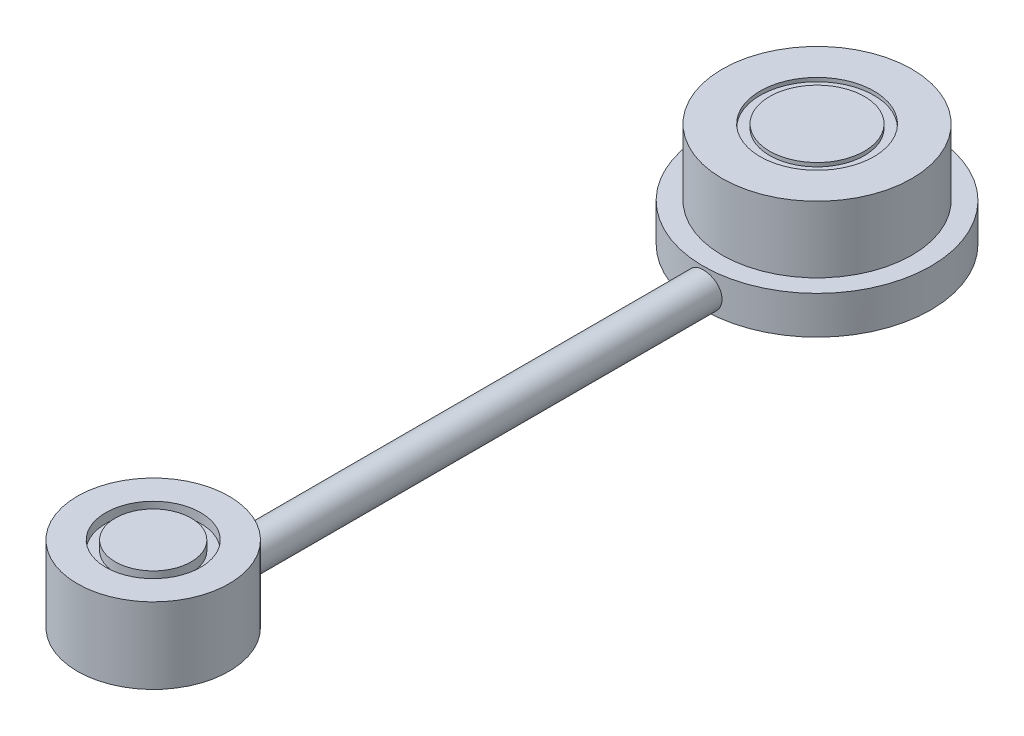
from build123d import *

# Parameters (mm, degrees)
SKETCH2_R            = 15.24
BOSS_EXTRUDE1_DEPTH  = 5.08
SKETCH3_R            = 12.7
BOSS_EXTRUDE4_DEPTH  = 8.89
SKETCH4_R            = 7.62
SKETCH4_R_2          = 6.35
CUT_EXTRUDE2_DEPTH   = 0.508
SKETCH7_R            = 10.16
BOSS_EXTRUDE7_DEPTH  = 10.16
SKETCH8_R            = 6.35
SKETCH8_R_2          = 5.08
CUT_EXTRUDE6_DEPTH   = 1.27
SKETCH11_R           = 2.33542976
BOSS_EXTRUDE8_DEPTH  = 82.55
SKETCH12_R           = 6.35
BOSS_EXTRUDE9_DEPTH  = 2.54
SKETCH13_R           = 5.715
BOSS_EXTRUDE13_DEPTH = 1.905


with BuildPart() as part:
    # Sketch2 → Boss-Extrude1 (new body)
    with BuildSketch(Plane(origin=(0, 0, 0), x_dir=(1, 0, 0), z_dir=(0, 1, 0))):
        Circle(SKETCH2_R)
    extrude(amount=BOSS_EXTRUDE1_DEPTH)

    # Sketch3 → Boss-Extrude4 (add)
    with BuildSketch(Plane(origin=(0, 5.08, 0), x_dir=(1, 0, 0), z_dir=(0, 1, 0))):
        Circle(SKETCH3_R)
    extrude(amount=BOSS_EXTRUDE4_DEPTH)

    # Sketch4 → Cut-Extrude2 (cut)
    with BuildSketch(Plane(origin=(0, 13.97, 0), x_dir=(1, 0, 0), z_dir=(0, 1, 0))):
        Circle(SKETCH4_R)
        Circle(SKETCH4_R_2, mode=Mode.SUBTRACT)
    extrude(amount=-CUT_EXTRUDE2_DEPTH, mode=Mode.SUBTRACT)



with BuildPart() as body_2:
    # Sketch7 → Boss-Extrude7 (new body)
    with BuildSketch(Plane(origin=(0, 0, 0), x_dir=(1, 0, 0), z_dir=(0, 1, 0))):
        with Locations((0, -88.9)):
            Circle(SKETCH7_R)
    extrude(amount=BOSS_EXTRUDE7_DEPTH)

    # Sketch8 → Cut-Extrude6 (cut)
    with BuildSketch(Plane(origin=(0, 10.16, 0), x_dir=(1, 0, 0), z_dir=(0, 1, 0))):
        with Locations((0, -88.9)):
            Circle(SKETCH8_R)
        with Locations((0, -88.9)):
            Circle(SKETCH8_R_2, mode=Mode.SUBTRACT)
    extrude(amount=-CUT_EXTRUDE6_DEPTH, mode=Mode.SUBTRACT)


with BuildPart() as part_1:
    add(part.part)

    add(body_2.part)  # Boss-Extrude8 merges body 2
    # Sketch11 → Boss-Extrude8 (add)
    with BuildSketch(Plane.XY):
        with Locations((0, 2.324561436)):
            Circle(SKETCH11_R)
    extrude(amount=BOSS_EXTRUDE8_DEPTH)

    # Sketch12 → Boss-Extrude9 (add)
    with BuildSketch(Plane.XZ):
        with Locations((-0.225047318, 0)):
            Circle(SKETCH12_R)
    extrude(amount=BOSS_EXTRUDE9_DEPTH)

    # Sketch13 → Boss-Extrude13 (add)
    with BuildSketch(Plane.XZ):
        with Locations((0, 88.9)):
            Circle(SKETCH13_R)
    extrude(amount=BOSS_EXTRUDE13_DEPTH)


solid = part_1.part
